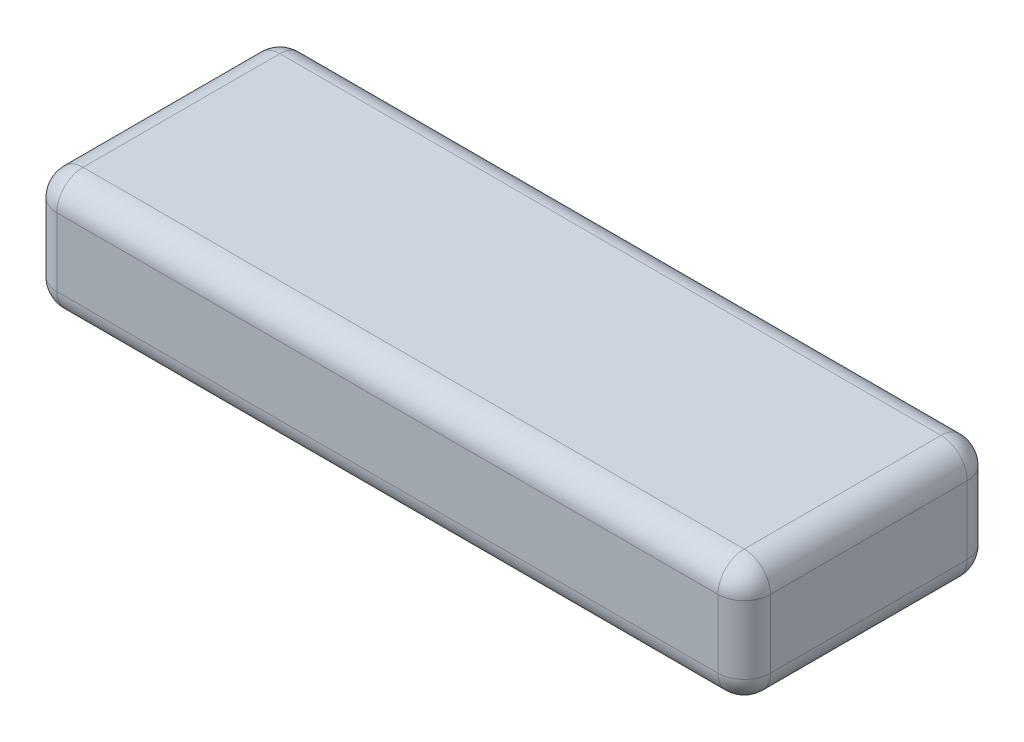
from build123d import *

# Parameters (mm, degrees)
SKETCH1_W           = 136
SKETCH1_H           = 47.5
BOSS_EXTRUDE1_DEPTH = 23
FILLET1_R           = 5


with BuildPart() as part:
    # Sketch1 → Boss-Extrude1 (new body)
    with BuildSketch(Plane(origin=(0, 0, 0), x_dir=(1, 0, 0), z_dir=(0, 1, 0))):
        Rectangle(SKETCH1_W, SKETCH1_H)
    extrude(amount=BOSS_EXTRUDE1_DEPTH)

    # Fillet1
    fillet1_edges = [part.edges().sort_by_distance(p)[0] for p in [
        (68, 23, 0),
        (0, 23, -23.75),
        (-68, 23, 0),
        (0, 0, -23.75),
        (68, 0, 0),
        (0, 0, 23.75),
        (-68, 0, 0),
        (-68, 11.5, -23.75),
        (68, 11.5, -23.75),
        (68, 11.5, 23.75),
        (-68, 11.5, 23.75),
        (0, 23, 23.75),
    ]]
    fillet(fillet1_edges, radius=FILLET1_R)


solid = part.part
